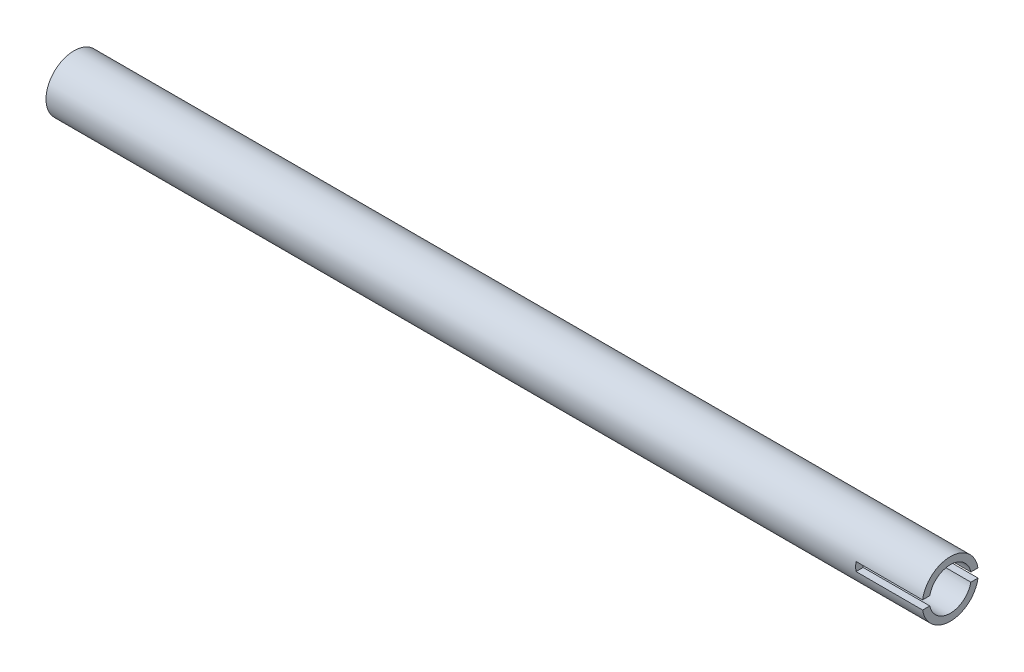
from build123d import *

# Parameters (mm, degrees)
SKETCH1_R               = 8
SKETCH1_R_2             = 6
BOSS_EXTRUDE1_DEPTH     = 125
SKETCH2_W               = 19
SKETCH2_H               = 2.5
CUT_EXTRUDE1_DEPTH      = 9
CUT_EXTRUDE1_DEPTH_BACK = 9


with BuildPart() as part:
    # Sketch1 → Boss-Extrude1 (new body, symmetric)
    with BuildSketch(Plane(origin=(0, 0, 0), x_dir=(0, 0, -1), z_dir=(1, 0, 0))):
        Circle(SKETCH1_R)
        Circle(SKETCH1_R_2, mode=Mode.SUBTRACT)
    extrude(amount=BOSS_EXTRUDE1_DEPTH, both=True)

    # Sketch2 → Cut-Extrude1 (cut, two sides)
    with BuildSketch(Plane.XY) as cut_extrude1_sk:
        with Locations((115.5, 0)):
            Rectangle(SKETCH2_W, SKETCH2_H)
    extrude(amount=CUT_EXTRUDE1_DEPTH, mode=Mode.SUBTRACT)
    extrude(cut_extrude1_sk.sketch, amount=-CUT_EXTRUDE1_DEPTH_BACK, mode=Mode.SUBTRACT)


solid = part.part
